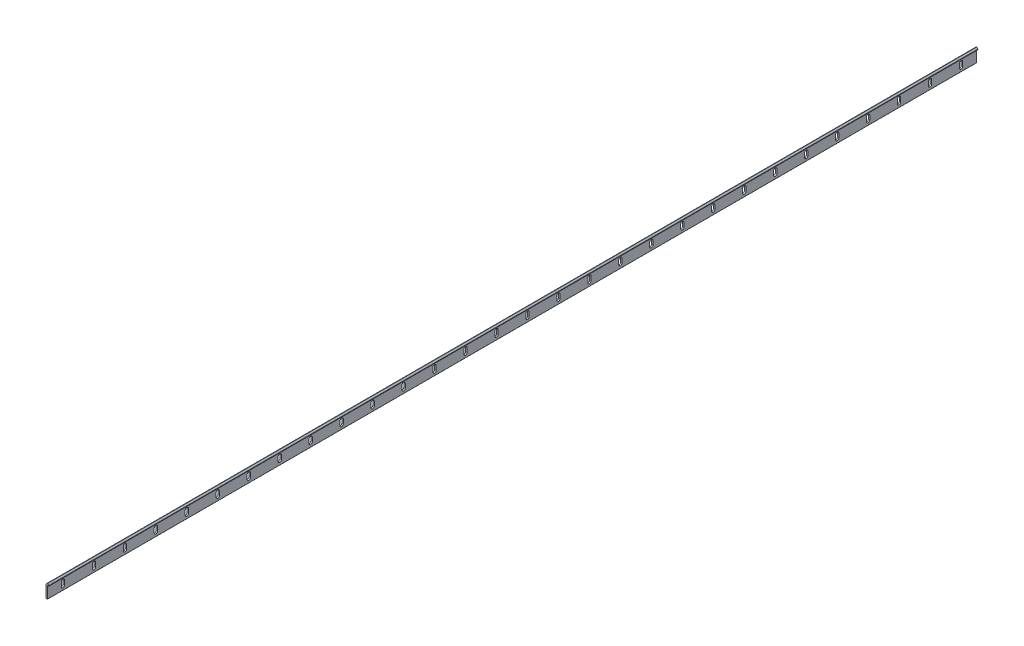
from build123d import *

# Parameters (mm, degrees)
BOSS_EXTRUDE1_DEPTH = 1500
FILLET1_R           = 0.50329666
FILLET2_R           = 0.50398302
FILLET3_R           = 0.30157619
FILLET4_R           = 0.30157551
CUT_EXTRUDE1_DEPTH  = 2.375
LPATTERN1_COUNT     = 30
LPATTERN1_PITCH     = 50


with BuildPart() as part:
    # Sketch1 → Boss-Extrude1 (new body)
    with BuildSketch(Plane.XY):
        with BuildLine():
            Line((0, 20.330194912), (2.019589054, 22.349783966))
            ThreePointArc((2.019589054, 22.349783966), (2.375, 22.497), (2.730410946, 22.349783966))
            Line((2.730410946, 22.349783966), (4.75, 20.330194912))
            Line((4.75, 20.330194912), (4.75, 19.5291))
            Line((4.75, 19.5291), (2.375, 19.5291))
            Line((2.375, 19.5291), (2.375, 0))
            Line((2.375, 0), (0, 0))
            Line((0, 0), (0, 20.330194912))
        make_face()
    extrude(amount=BOSS_EXTRUDE1_DEPTH)

    # Fillet1
    fillet1_edges = [part.edges().sort_by_distance(p)[0] for p in [
        (0, 20.330194912, 750),
    ]]
    fillet(fillet1_edges, radius=FILLET1_R)

    # Fillet2
    fillet2_edges = [part.edges().sort_by_distance(p)[0] for p in [
        (4.75, 20.330194912, 750),
    ]]
    fillet(fillet2_edges, radius=FILLET2_R)

    # Fillet3
    fillet3_edges = [part.edges().sort_by_distance(p)[0] for p in [
        (4.75, 19.5291, 750),
    ]]
    fillet(fillet3_edges, radius=FILLET3_R)

    # Fillet4
    fillet4_edges = [part.edges().sort_by_distance(p)[0] for p in [
        (2.375, 0, 750),
        (0, 0, 750),
    ]]
    fillet(fillet4_edges, radius=FILLET4_R)

    # Sketch2 → Cut-Extrude1 (cut)
    with BuildSketch(Plane.ZY):
        with BuildLine():
            Line((27.65, 13.1043), (27.65, 6.4043))
            ThreePointArc((27.65, 6.4043), (25, 3.7543), (22.35, 6.4043))
            Line((22.35, 6.4043), (22.35, 13.1043))
            ThreePointArc((22.35, 13.1043), (25, 15.7543), (27.65, 13.1043))
        make_face()
    cut_extrude1 = extrude(amount=-CUT_EXTRUDE1_DEPTH, mode=Mode.SUBTRACT)

    # LPattern1: Cut-Extrude1 ×30
    with Locations(*[(0, 0, i * LPATTERN1_PITCH) for i in range(1, LPATTERN1_COUNT)]):
        add(cut_extrude1, mode=Mode.SUBTRACT)


solid = part.part
